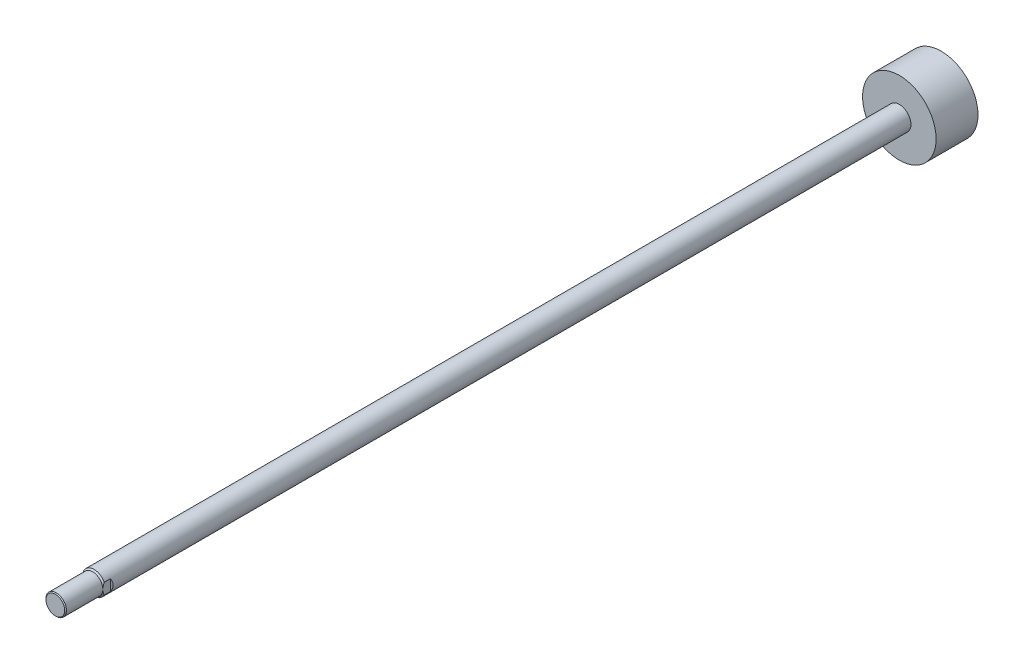
from build123d import *

# Parameters (mm, degrees)
CUT_EXTRUDE_1_DEPTH      = 12.5
CUT_EXTRUDE_1_DEPTH_BACK = 12.5
CUT_EXTRUDE_2_DEPTH      = 12.5
CUT_EXTRUDE_2_DEPTH_BACK = 12.5


with BuildPart() as part:
    # 草图1 → 旋转1 (revolve)
    with BuildSketch(Plane(origin=(0, 0, 0), x_dir=(0, 0, -1), z_dir=(1, 0, 0))):
        Polygon((-52, 0), (-52, 10.08), (-51.08, 11), (-12, 11), (-10.5, 12.5), (854.5, 12.5), (854.5, 39.5), (899.5, 39.5), (899.5, 0), align=None)
    revolve(axis=Axis((0, 0, -899.5), (0, 0, 1)))

    # 草图2 → 切除-拉伸1 (cut, two sides: drawn at the far end of the back side and taken through both)
    with BuildSketch(Plane(origin=(0, 0, 0), x_dir=(1, 0, 0), z_dir=(0, 1, 0)).offset(-CUT_EXTRUDE_1_DEPTH_BACK)):
        Polygon((11, -3.9), (11, -12), (12.5, -12), (12.5, -2.4), align=None)
    extrude(amount=CUT_EXTRUDE_1_DEPTH + CUT_EXTRUDE_1_DEPTH_BACK, mode=Mode.SUBTRACT)

    # 草图3 → 切除-拉伸2 (cut, two sides: drawn at the far end of the back side and taken through both)
    with BuildSketch(Plane(origin=(0, 0, 0), x_dir=(1, 0, 0), z_dir=(0, 1, 0)).offset(-CUT_EXTRUDE_2_DEPTH_BACK)):
        Polygon((-12.5, -2.4), (-12.5, -12), (-11, -12), (-11, -3.9), align=None)
    extrude(amount=CUT_EXTRUDE_2_DEPTH + CUT_EXTRUDE_2_DEPTH_BACK, mode=Mode.SUBTRACT)


solid = part.part
